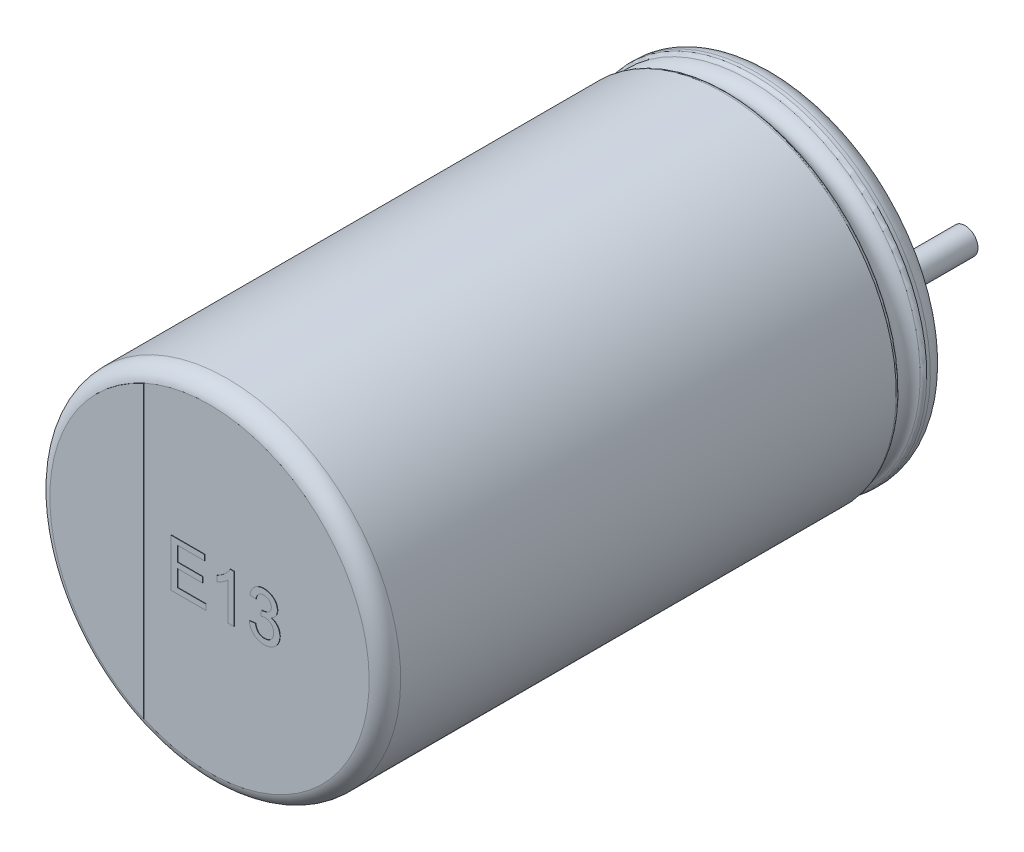
from build123d import *

# Parameters (mm, degrees)
SKETCH_2_R         = 0.3
EXTRUDE_1_DEPTH    = 2.7
EXTRUDE_2_DEPTH    = 0.01
EXTRUDE_1791_DEPTH = 0.01
EXTRUDE_5_DEPTH    = 0.05


with BuildPart() as part:
    # Sketch10 → Повернуть1 (revolve)
    with BuildSketch(Plane(origin=(0, 0, 0), x_dir=(0, 0, -1), z_dir=(1, 0, 0))):
        with BuildLine():
            Line((-13, 0), (-0.05, 0))
            Line((-0.05, 0), (-0.05, 3.403143426))
            ThreePointArc((-0.05, 3.403143426), (-0.052704561, 3.801565585), (-0.398206102, 4))
            Line((-0.398206102, 4), (-0.479422929, 4))
            ThreePointArc((-0.479422929, 4), (-0.534479696, 3.983479053), (-0.571344666, 3.939375046))
            ThreePointArc((-0.571344666, 3.939375046), (-0.831990181, 3.767472047), (-1.092635697, 3.939375046))
            ThreePointArc((-1.092635697, 3.939375046), (-1.129500666, 3.983479053), (-1.184557434, 4))
            Line((-1.184557434, 4), (-12.6, 4))
            ThreePointArc((-12.6, 4), (-12.85971595, 3.909961924), (-13, 3.67357323))
            Line((-13, 3.67357323), (-13, 0))
        make_face()
    revolve(axis=Axis((0, 0, -18.1630778), (0, 0, 1)))

    # Эскиз2 → Бобышка-Вытянуть1 (add)
    with BuildSketch(Plane(origin=(0, 0, 0.05), x_dir=(-1, 0, 0), z_dir=(0, 0, -1))):
        with Locations(Location((-1.75, 0, 0), (0, 0, 90))):
            Circle(SKETCH_2_R)
        with Locations(Location((1.75, 0, 0), (0, 0, 270))):
            Circle(SKETCH_2_R)
    extrude(amount=EXTRUDE_1_DEPTH)

    # Эскиз4 → Бобышка-Вытянуть2 (add)
    with BuildSketch(Plane.XY.offset(13)):
        with BuildLine():
            Line((-1.509635526, -3.349050739), (-1.509635526, 3.349050739))
            ThreePointArc((-1.509635526, 3.349050739), (-3.67357323, 0), (-1.509635526, -3.349050739))
        make_face()
    extrude(amount=EXTRUDE_2_DEPTH)

    # Эскиз5 → Extrude 1791 (add)
    with BuildSketch(Plane.XY.offset(13)):
        Polygon((-0.884369756, -0.464160183), (-0.884369756, 0.635839817), (-0.108728731, 0.635839817), (-0.108728731, 0.50891674), (-0.729241551, 0.50891674), (-0.729241551, 0.170455202), (-0.151036423, 0.170455202), (-0.151036423, 0.043532125), (-0.729241551, 0.043532125), (-0.729241551, -0.337237106), (-0.080523602, -0.337237106), (-0.080523602, -0.464160183), align=None)
        with BuildLine():
            Line((0.568194346, -0.464160183), (0.427168705, -0.464160183))
            Line((0.427168705, -0.464160183), (0.427168705, 0.393011291))
            add(Edge.make_bspline(
                [(0.427168705, 0.393011291), (0.419048436, 0.385180291), (0.402171347, 0.368904415), (0.373642411, 0.345869987), (0.341800473, 0.322523617), (0.30705902, 0.300073472), (0.271645985, 0.278939082), (0.237423847, 0.259931947), (0.204963957, 0.2438473), (0.183582453, 0.235052151), (0.173322551, 0.230831804)],
                knots=[0, 0, 0, 0, 0.893362401, 1.856755847, 2.901947673, 4.020460078, 5.132200827, 6.168787962, 7.121294059, 8, 8, 8, 8], degree=3))
            Line((0.173322551, 0.230831804), (0.173322551, 0.360839817))
            add(Edge.make_bspline(
                [(0.173322551, 0.360839817), (0.190944992, 0.369915409), (0.22567778, 0.387802865), (0.274747698, 0.418696959), (0.320559746, 0.452187428), (0.362355551, 0.488266859), (0.399822828, 0.525146514), (0.431397045, 0.562359534), (0.457816342, 0.598541851), (0.471071403, 0.623775005), (0.47740909, 0.635839817)],
                knots=[0, 0, 0, 0, 1.141258006, 2.249351951, 3.335817539, 4.406819942, 5.426913362, 6.360259544, 7.215985427, 8, 8, 8, 8], degree=3))
            Line((0.47740909, 0.635839817), (0.568194346, 0.635839817))
            Line((0.568194346, 0.635839817), (0.568194346, -0.464160183))
        make_face()
        with BuildLine():
            Line((0.920758449, -0.168006337), (1.06178409, -0.153903773))
            add(Edge.make_bspline(
                [(1.06178409, -0.153903773), (1.063664131, -0.162377428), (1.06730187, -0.178773324), (1.074301325, -0.202262147), (1.081694286, -0.224065027), (1.090859297, -0.243694287), (1.099802355, -0.261952681), (1.110311803, -0.278085789), (1.121541353, -0.292514547), (1.1336986, -0.305185376), (1.146923636, -0.316096508), (1.161040141, -0.325644336), (1.176346666, -0.333618059), (1.192726022, -0.339931304), (1.210040253, -0.345041929), (1.228383456, -0.348794569), (1.247852625, -0.351030063), (1.26119716, -0.351234784), (1.26803409, -0.35133967)],
                knots=[0, 0, 0, 0, 1.321063709, 2.556160278, 3.730472002, 4.821700466, 5.852032229, 6.822994757, 7.746964065, 8.632786469, 9.490489437, 10.352773447, 11.223141997, 12.11199479, 13.021433979, 13.96892724, 14.959401504, 16, 16, 16, 16], degree=3))
            add(Edge.make_bspline(
                [(1.26803409, -0.35133967), (1.276053567, -0.351225332), (1.291715618, -0.351002029), (1.31453781, -0.347651632), (1.33625715, -0.343051218), (1.356563762, -0.335837506), (1.375740402, -0.327021016), (1.393677821, -0.316125705), (1.4104988, -0.303331883), (1.425871557, -0.288552526), (1.439619375, -0.272294762), (1.451863739, -0.255122414), (1.461988182, -0.236888955), (1.470521564, -0.217851209), (1.476820315, -0.197701536), (1.48143151, -0.176691191), (1.484444949, -0.154725157), (1.484720422, -0.139737851), (1.484861013, -0.132088869)],
                knots=[0, 0, 0, 0, 1.111377895, 2.170522867, 3.193923215, 4.186422864, 5.152846954, 6.117443035, 7.091571248, 8.078879332, 9.069127402, 10.041602243, 10.999610288, 11.957618333, 12.930786866, 13.922135183, 14.939532534, 16, 16, 16, 16], degree=3))
            add(Edge.make_bspline(
                [(1.484861013, -0.132088869), (1.484695777, -0.124809694), (1.484372506, -0.11056857), (1.481714956, -0.089665655), (1.477077591, -0.06982315), (1.470649093, -0.050926221), (1.462434793, -0.033002608), (1.452561447, -0.015904101), (1.440485535, -5.414e-06), (1.42689303, 0.014864219), (1.412067574, 0.028563417), (1.395843389, 0.040216348), (1.378769448, 0.050273208), (1.360642271, 0.058393729), (1.341537121, 0.064839032), (1.321472211, 0.069471399), (1.300351073, 0.072130102), (1.285963617, 0.072453429), (1.278611013, 0.072618663)],
                knots=[0, 0, 0, 0, 1.072815875, 2.098878726, 3.09954706, 4.07199174, 5.036203424, 6.001873089, 6.97636515, 7.972747947, 8.969130744, 9.945905975, 10.911575641, 11.885646534, 12.868345115, 13.879560892, 14.916365174, 16, 16, 16, 16], degree=3))
            add(Edge.make_bspline(
                [(1.278611013, 0.072618663), (1.272137492, 0.072447159), (1.258399171, 0.072083188), (1.236715503, 0.068869458), (1.212697167, 0.064369483), (1.196099812, 0.059953425), (1.187385051, 0.057634689)],
                knots=[0, 0, 0, 0, 0.837610211, 1.777604146, 2.833088267, 4, 4, 4, 4], degree=3))
            Line((1.187385051, 0.057634689), (1.201928321, 0.184557766))
            add(Edge.make_bspline(
                [(1.201928321, 0.184557766), (1.205744134, 0.184140802), (1.212485364, 0.183404169), (1.219260588, 0.183132982), (1.222200757, 0.183015298)],
                knots=[0, 0, 0, 0, 1.132082448, 2, 2, 2, 2], degree=3))
            add(Edge.make_bspline(
                [(1.222200757, 0.183015298), (1.235170445, 0.183510476), (1.260612898, 0.184481859), (1.297703062, 0.192553238), (1.332853659, 0.205261365), (1.360009766, 0.220424003), (1.380147818, 0.234685288), (1.392846468, 0.24754386), (1.404294956, 0.261189402), (1.412836464, 0.276841333), (1.4202158, 0.293471887), (1.424785438, 0.311736188), (1.428117991, 0.331190275), (1.428337843, 0.344664705), (1.428450757, 0.351585009)],
                knots=[0, 0, 0, 0, 1.557468908, 3.055264441, 4.54122591, 6.035034992, 6.780215604, 7.498173296, 8.201377046, 8.913174237, 9.633083494, 10.382644491, 11.169345745, 12, 12, 12, 12], degree=3))
            add(Edge.make_bspline(
                [(1.428450757, 0.351585009), (1.428346546, 0.357174773), (1.428142739, 0.368106772), (1.425872235, 0.384134239), (1.422117102, 0.399320756), (1.417041666, 0.413828476), (1.410389803, 0.427581365), (1.40214097, 0.440562586), (1.392716399, 0.453035475), (1.381591026, 0.464355514), (1.369676717, 0.474983349), (1.356539006, 0.483934166), (1.34280315, 0.491885651), (1.327984716, 0.497894218), (1.312449536, 0.502834239), (1.296064815, 0.506296005), (1.278824571, 0.508620814), (1.267013764, 0.50881671), (1.260982808, 0.50891674)],
                knots=[0, 0, 0, 0, 1.041493611, 2.036867705, 3.009952345, 3.954088258, 4.897230656, 5.850851638, 6.817653571, 7.805463921, 8.805067469, 9.788883576, 10.763797054, 11.758134544, 12.762883247, 13.799594994, 14.876406454, 16, 16, 16, 16], degree=3))
            add(Edge.make_bspline(
                [(1.260982808, 0.50891674), (1.249180379, 0.508456544), (1.22638814, 0.507567837), (1.193756131, 0.499345454), (1.164185639, 0.486040568), (1.142293073, 0.470437651), (1.126747426, 0.45552038), (1.116128925, 0.442876273), (1.106631279, 0.42891349), (1.098227567, 0.413637011), (1.091031328, 0.396985397), (1.084544118, 0.379164938), (1.079522415, 0.359890328), (1.077119119, 0.346534924), (1.075886654, 0.339685971)],
                knots=[0, 0, 0, 0, 1.533565899, 2.961543033, 4.347411787, 5.731829577, 6.434842101, 7.147085226, 7.87612511, 8.629021686, 9.412189982, 10.234506416, 11.094615066, 12, 12, 12, 12], degree=3))
            Line((1.075886654, 0.339685971), (0.934861013, 0.353788535))
            add(Edge.make_bspline(
                [(0.934861013, 0.353788535), (0.937067075, 0.364692791), (0.941394439, 0.386082348), (0.950210689, 0.416974696), (0.960961997, 0.445973814), (0.97387075, 0.472946746), (0.988327095, 0.498216295), (1.005003538, 0.521482725), (1.0235091, 0.542884358), (1.043876651, 0.562355915), (1.065829689, 0.579746194), (1.089257644, 0.594747591), (1.11396825, 0.607463437), (1.139984643, 0.617714658), (1.167286225, 0.626050455), (1.195950667, 0.63157294), (1.225848223, 0.635308624), (1.246207241, 0.635660574), (1.256575757, 0.635839817)],
                knots=[0, 0, 0, 0, 1.136581168, 2.229493434, 3.279335563, 4.293305329, 5.282068175, 6.250623624, 7.213783178, 8.169396253, 9.125981663, 10.071280146, 11.007896369, 11.961295906, 12.925420184, 13.920544621, 14.940967302, 16, 16, 16, 16], degree=3))
            add(Edge.make_bspline(
                [(1.256575757, 0.635839817), (1.27092825, 0.635374401), (1.299149893, 0.634459243), (1.34060091, 0.627190944), (1.380248589, 0.61526352), (1.417773889, 0.598729984), (1.452531206, 0.578526439), (1.483288567, 0.554313721), (1.509634787, 0.526510705), (1.53105815, 0.495421358), (1.548022448, 0.462320493), (1.560575518, 0.42796036), (1.568076166, 0.392380513), (1.569008705, 0.368292965), (1.569476398, 0.356212413)],
                knots=[0, 0, 0, 0, 1.104647871, 2.172094857, 3.229560912, 4.285649672, 5.322588163, 6.317201348, 7.289435229, 8.260615662, 9.214246199, 10.146367077, 11.070353327, 12, 12, 12, 12], degree=3))
            add(Edge.make_bspline(
                [(1.569476398, 0.356212413), (1.56900225, 0.344792705), (1.568066069, 0.322245037), (1.560858581, 0.289276353), (1.54867936, 0.258042232), (1.532217625, 0.228433088), (1.510870795, 0.201089242), (1.484697502, 0.176723383), (1.45411645, 0.155102367), (1.431198538, 0.143848867), (1.419416301, 0.138063375)],
                knots=[0, 0, 0, 0, 0.975609618, 1.926294443, 2.868398979, 3.832526731, 4.812148358, 5.820404151, 6.879456693, 8, 8, 8, 8], degree=3))
            add(Edge.make_bspline(
                [(1.419416301, 0.138063375), (1.427315505, 0.136068982), (1.442787738, 0.132162549), (1.465009374, 0.124068531), (1.485900207, 0.114592471), (1.505738279, 0.103859719), (1.523947656, 0.091166499), (1.541155997, 0.077287902), (1.556712787, 0.061555526), (1.571068735, 0.044530099), (1.584130885, 0.026389796), (1.595122813, 0.006781747), (1.604608527, -0.013778587), (1.612697042, -0.035440329), (1.61850943, -0.058370507), (1.622665472, -0.082391482), (1.62540812, -0.107419796), (1.625725579, -0.124516158), (1.625886654, -0.133190632)],
                knots=[0, 0, 0, 0, 1.053251915, 2.063013066, 3.05373318, 4.018979697, 4.975584284, 5.920798056, 6.874756953, 7.832116109, 8.799604348, 9.761196922, 10.734637845, 11.72654167, 12.747371341, 13.789206138, 14.878271633, 16, 16, 16, 16], degree=3))
            add(Edge.make_bspline(
                [(1.625886654, -0.133190632), (1.625618245, -0.145033375), (1.625090736, -0.168308166), (1.620089932, -0.202499364), (1.611917495, -0.235259128), (1.600607938, -0.266698705), (1.58627694, -0.296946404), (1.568293902, -0.32557538), (1.547191799, -0.352818347), (1.523300534, -0.378414463), (1.497125367, -0.401938082), (1.468700136, -0.422307287), (1.438587234, -0.439605137), (1.406737655, -0.453711448), (1.373235834, -0.464794131), (1.338048441, -0.472738552), (1.301066592, -0.47740757), (1.27583332, -0.477973936), (1.262965981, -0.478262747)],
                knots=[0, 0, 0, 0, 1.016055063, 1.996874249, 2.958724482, 3.910019225, 4.860394196, 5.826121543, 6.806008102, 7.814207964, 8.82789325, 9.821757317, 10.810247154, 11.803791187, 12.806673825, 13.834534493, 14.895752369, 16, 16, 16, 16], degree=3))
            add(Edge.make_bspline(
                [(1.262965981, -0.478262747), (1.251418611, -0.478045241), (1.228685765, -0.477617047), (1.195409571, -0.47315599), (1.163529247, -0.466825238), (1.133296886, -0.457065622), (1.104361311, -0.445163929), (1.077212586, -0.429937507), (1.051362556, -0.412458166), (1.027296523, -0.392226514), (1.00514814, -0.36989606), (0.985389132, -0.345797089), (0.968421938, -0.319983108), (0.95346203, -0.292840343), (0.941370555, -0.263857141), (0.931955428, -0.23328234), (0.924776267, -0.201229412), (0.922112294, -0.17920119), (0.920758449, -0.168006337)],
                knots=[0, 0, 0, 0, 1.08471039, 2.135426191, 3.150939737, 4.135689946, 5.116584603, 6.086901885, 7.055842759, 8.045878862, 9.036901429, 10.008421467, 10.96965771, 11.936653536, 12.917548193, 13.915472582, 14.940632654, 16, 16, 16, 16], degree=3))
        make_face()
    extrude(amount=EXTRUDE_1791_DEPTH)

    # Эскиз6 → Бобышка-Вытянуть5 (add)
    with BuildSketch(Plane(origin=(0, 0, 0.05), x_dir=(-1, 0, 0), z_dir=(0, 0, -1))):
        with BuildLine():
            Line((-1.75, 0.465643654), (-2.133155916, 0.465643654))
            ThreePointArc((-2.133155916, 0.465643654), (-2.336107869, 0.569662474), (-2.37017324, 0.795159615))
            ThreePointArc((-2.37017324, 0.795159615), (0, 2.5), (2.37017324, 0.795159615))
            ThreePointArc((2.37017324, 0.795159615), (2.336107869, 0.569662474), (2.133155916, 0.465643654))
            Line((2.133155916, 0.465643654), (1.75, 0.465643654))
            ThreePointArc((1.75, 0.465643654), (1.284356346, 0), (1.75, -0.465643654))
            Line((1.75, -0.465643654), (2.133155916, -0.465643654))
            ThreePointArc((2.133155916, -0.465643654), (2.336107869, -0.569662474), (2.37017324, -0.795159615))
            ThreePointArc((2.37017324, -0.795159615), (0, -2.5), (-2.37017324, -0.795159615))
            ThreePointArc((-2.37017324, -0.795159615), (-2.336107869, -0.569662474), (-2.133155916, -0.465643654))
            Line((-2.133155916, -0.465643654), (-1.75, -0.465643654))
            ThreePointArc((-1.75, -0.465643654), (-1.284356346, 0), (-1.75, 0.465643654))
        make_face()
    extrude(amount=EXTRUDE_5_DEPTH)


solid = part.part
